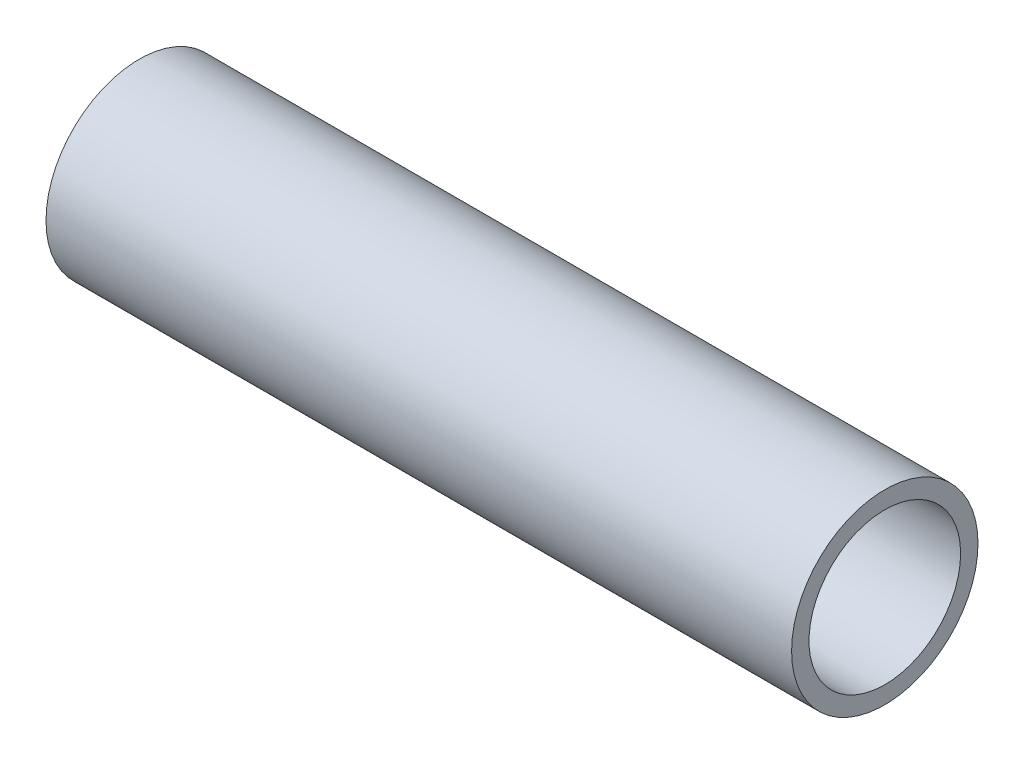
from build123d import *

# Parameters (mm, degrees)
SKETCH1_R      = 4.7625
SKETCH1_R_2    = 3.8735
EXTRUDE1_DEPTH = 19.05


with BuildPart() as part:
    # Sketch1 → Extrude1 (new body, symmetric)
    with BuildSketch(Plane(origin=(0, 0, 0), x_dir=(0, 0, -1), z_dir=(1, 0, 0))):
        Circle(SKETCH1_R)
        Circle(SKETCH1_R_2, mode=Mode.SUBTRACT)
    extrude(amount=EXTRUDE1_DEPTH, both=True)


solid = part.part
